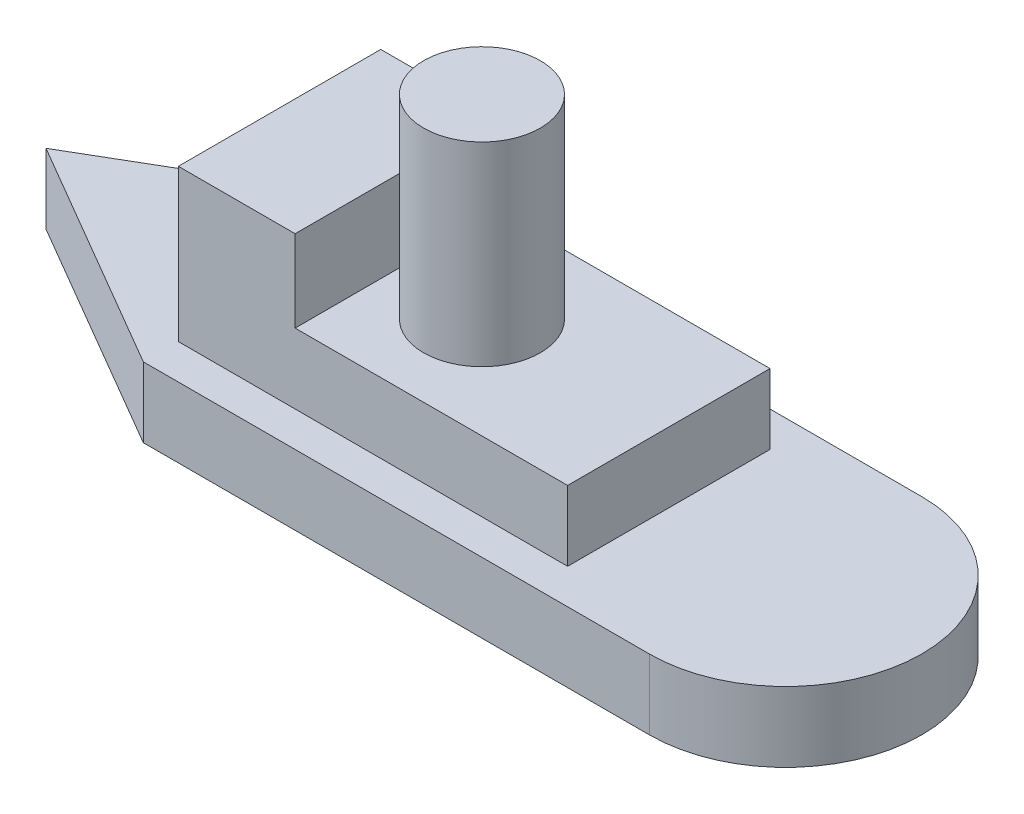
from build123d import *

# Parameters (mm, degrees)
BOSS_EXTRUDE1_DEPTH = 18
SKETCH2_W           = 100
SKETCH2_H           = 52
BOSS_EXTRUDE2_DEPTH = 18
SKETCH3_W           = 30
SKETCH3_H           = 52
BOSS_EXTRUDE3_DEPTH = 21
SKETCH4_R           = 15
BOSS_EXTRUDE4_DEPTH = 50


with BuildPart() as part:
    # Sketch1 → Boss-Extrude1 (new body)
    with BuildSketch(Plane(origin=(0, 0, 0), x_dir=(1, 0, 0), z_dir=(0, 1, 0))):
        with BuildLine():
            Line((0, 0), (60, 35))
            Line((60, 35), (190, 35))
            ThreePointArc((190, 35), (225, 0), (190, -35))
            Line((190, -35), (60, -35))
            Line((60, -35), (0, 0))
        make_face()
    extrude(amount=BOSS_EXTRUDE1_DEPTH)

    # Sketch2 → Boss-Extrude2 (add)
    with BuildSketch(Plane(origin=(0, 18, 0), x_dir=(1, 0, 0), z_dir=(0, 1, 0))):
        with Locations((110, 0)):
            Rectangle(SKETCH2_W, SKETCH2_H)
    extrude(amount=BOSS_EXTRUDE2_DEPTH)

    # Sketch3 → Boss-Extrude3 (add)
    with BuildSketch(Plane(origin=(0, 36, 0), x_dir=(1, 0, 0), z_dir=(0, 1, 0))):
        with Locations((75, 0)):
            Rectangle(SKETCH3_W, SKETCH3_H)
    extrude(amount=BOSS_EXTRUDE3_DEPTH)

    # Sketch4 → Boss-Extrude4 (add)
    with BuildSketch(Plane(origin=(0, 36, 0), x_dir=(1, 0, 0), z_dir=(0, 1, 0))):
        with Locations(Location((112, 0, 0), (0, 0, 270))):  # turned: the seam where the file's is
            Circle(SKETCH4_R)
    extrude(amount=BOSS_EXTRUDE4_DEPTH)


solid = part.part
